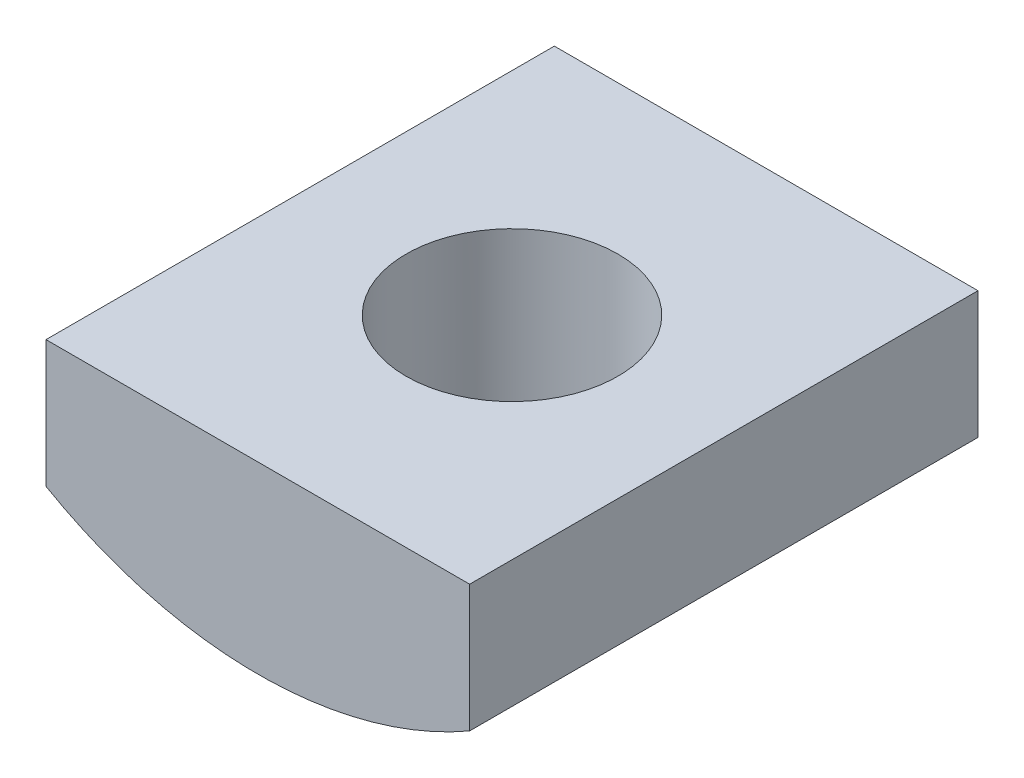
from build123d import *

# Parameters (mm, degrees)
EXTRUDE_1_DEPTH = 12
M6X1_0_1_D      = 5
M6X1_0_1_DEPTH  = 15
M6X1_0_1_TIP    = 1.502151548


with BuildPart() as part:
    # 草圖1 → 填料-伸長1 (new body)
    with BuildSketch(Plane.XY):
        with BuildLine():
            Line((-5, 0), (5, 0))
            Line((5, 0), (5, -3))
            ThreePointArc((5, -3), (0, -4.339745962), (-5, -3))
            Line((-5, -3), (-5, 0))
        make_face()
    extrude(amount=EXTRUDE_1_DEPTH)

    # M6x1.0 螺紋孔1
    with Locations(Plane(origin=(0, 0, 0), x_dir=(1, 0, 0), z_dir=(0, 1, 0))):
        with Locations((0, -6)):
            Hole(M6X1_0_1_D / 2, depth=M6X1_0_1_DEPTH)
            with Locations((0, 0, -(M6X1_0_1_DEPTH + M6X1_0_1_TIP / 2))):  # 118° drill point
                Cone(0, M6X1_0_1_D / 2, M6X1_0_1_TIP, mode=Mode.SUBTRACT)


solid = part.part
